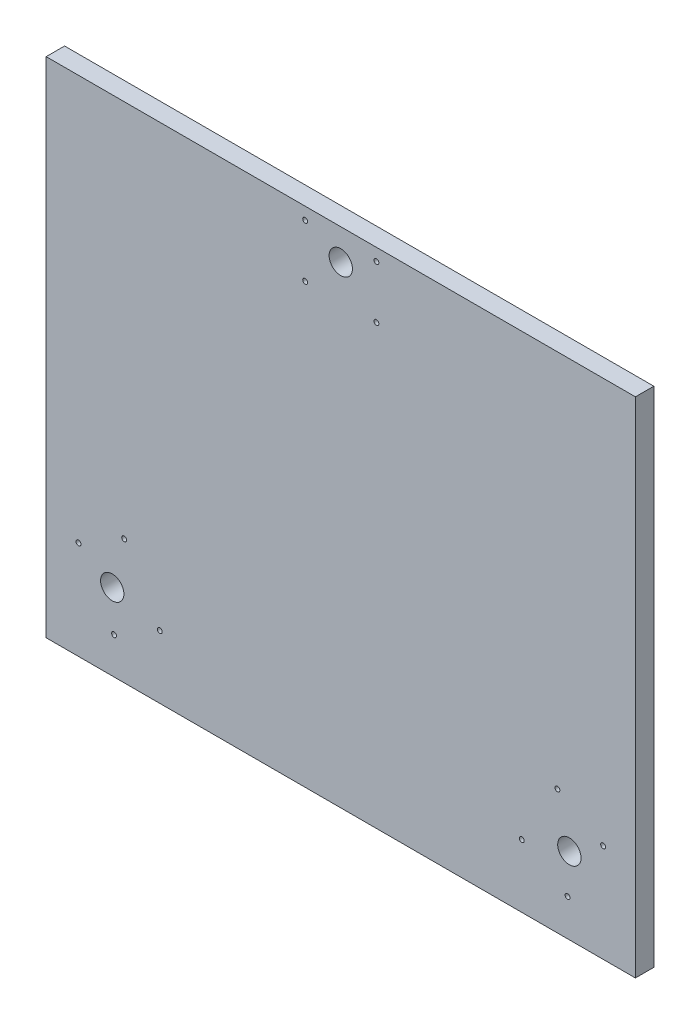
from build123d import *

# Parameters (mm, degrees)
SKETCH1_W           = 480
SKETCH1_H           = 410
BOSS_EXTRUDE1_DEPTH = 15
SKETCH6_R           = 2
SKETCH6_R_2         = 9.5
CUT_EXTRUDE1_DEPTH  = 340.742549587
CIRPATTERN1_COUNT   = 3
CIRPATTERN1_ANGLE   = 180
CIRPATTERN2_COUNT   = 6
CIRPATTERN2_ANGLE   = 150
SKETCH8_W           = 471.000952056
SKETCH8_H           = 87.60062656
BOSS_EXTRUDE2_DEPTH = 15


with BuildPart() as part:
    # Sketch1 → Boss-Extrude1 (new body)
    with BuildSketch(Plane.XY):
        with Locations((0, 35)):
            Rectangle(SKETCH1_W, SKETCH1_H)
    extrude(amount=BOSS_EXTRUDE1_DEPTH)

    # Sketch6 → Cut-Extrude1 (cut, through all)
    with BuildSketch(Plane.XY.offset(15)):
        with Locations((-230, 29)):
            Circle(SKETCH6_R)
        with Locations((-187, 29)):
            Circle(SKETCH6_R)
        with Locations(Location((-230, -29, 0), (0, 0, 180))):
            Circle(SKETCH6_R)
        with Locations(Location((-187, -29, 0), (0, 0, 180))):
            Circle(SKETCH6_R)
        with Locations((-215, 0)):
            Circle(SKETCH6_R_2)
    cut_extrude1 = extrude(amount=-CUT_EXTRUDE1_DEPTH, mode=Mode.SUBTRACT)

    # CirPattern1: Cut-Extrude1 ×3 about axis
    cirpattern1_axis = Axis((0, 0, 0), (0, 0, -1))
    for i in range(1, CIRPATTERN1_COUNT):
        add(cut_extrude1.rotate(cirpattern1_axis, i * CIRPATTERN1_ANGLE / (CIRPATTERN1_COUNT - 1)), mode=Mode.SUBTRACT)

    # CirPattern2: Cut-Extrude1 ×6 about axis, 3 skipped
    cirpattern2_axis = Axis((0, 0, 0), (0, 0, 1))
    add([cut_extrude1.rotate(cirpattern2_axis, i * CIRPATTERN2_ANGLE / (CIRPATTERN2_COUNT - 1)) for i in range(1, CIRPATTERN2_COUNT) if i not in (2, 3, 4)], mode=Mode.SUBTRACT)

    # Sketch8 → Boss-Extrude2 (add)
    with BuildSketch(Plane(origin=(0, 0, 0), x_dir=(-1, 0, 0), z_dir=(0, 0, -1))):
        Rectangle(SKETCH8_W, SKETCH8_H)
    extrude(amount=-BOSS_EXTRUDE2_DEPTH)


solid = part.part
